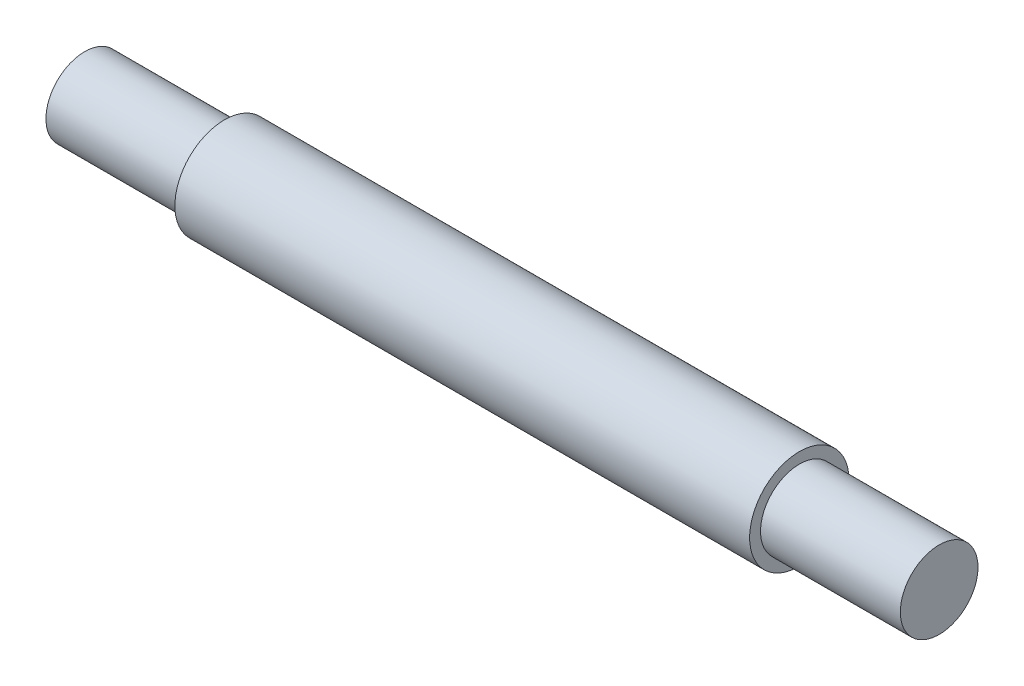
from build123d import *

# Parameters (mm, degrees)
SKETCH1_R           = 3.175
BOSS_EXTRUDE1_DEPTH = 34.925
SKETCH2_R           = 4.064
BOSS_EXTRUDE2_DEPTH = 23.495


with BuildPart() as part:
    # Sketch1 → Boss-Extrude1 (new body, symmetric)
    with BuildSketch(Plane(origin=(0, 0, 0), x_dir=(0, 0, -1), z_dir=(1, 0, 0))):
        Circle(SKETCH1_R)
    extrude(amount=BOSS_EXTRUDE1_DEPTH, both=True)

    # Sketch2 → Boss-Extrude2 (add, symmetric)
    with BuildSketch(Plane(origin=(0, 0, 0), x_dir=(0, 0, -1), z_dir=(1, 0, 0))):
        Circle(SKETCH2_R)
    extrude(amount=BOSS_EXTRUDE2_DEPTH, both=True)


solid = part.part
